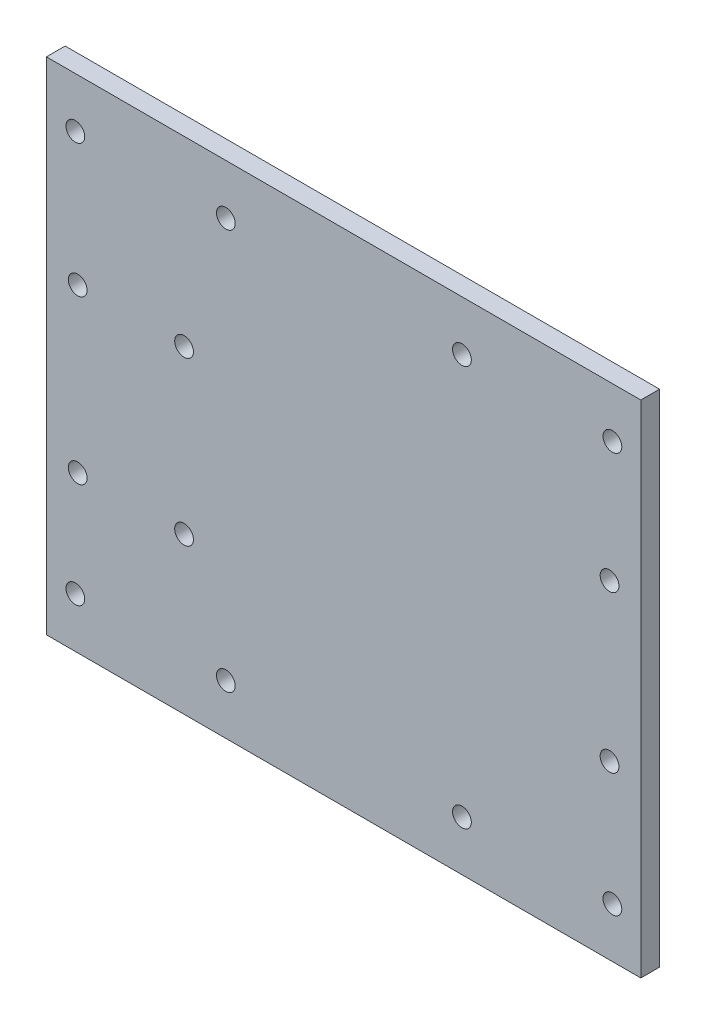
from build123d import *

# Parameters (mm, degrees)
SKETCH1_W           = 95
SKETCH1_H           = 80
BOSS_EXTRUDE1_DEPTH = 3
SKETCH2_R           = 1.5
CUT_EXTRUDE1_DEPTH  = 3


with BuildPart() as part:
    # Sketch1 → Boss-Extrude1 (new body)
    with BuildSketch(Plane.XY):
        Rectangle(SKETCH1_W, SKETCH1_H)
    extrude(amount=BOSS_EXTRUDE1_DEPTH)

    # Sketch2 → Cut-Extrude1 (cut)
    with BuildSketch(Plane.XY.offset(3)):
        with Locations((-42.875692348, -32)):
            Circle(SKETCH2_R)
        with Locations((-18.825692348, -32)):
            Circle(SKETCH2_R)
        with Locations((-42.875692348, 32)):
            Circle(SKETCH2_R)
        with Locations((-18.825692348, 32)):
            Circle(SKETCH2_R)
        with Locations((-42.5, 10.92769595)):
            Circle(SKETCH2_R)
        with Locations((-25.5, 10.92769595)):
            Circle(SKETCH2_R)
        with Locations((-42.5, -15.07230405)):
            Circle(SKETCH2_R)
        with Locations((-25.5, -15.07230405)):
            Circle(SKETCH2_R)
        with Locations((42.5, -12.5)):
            Circle(SKETCH2_R)
        with Locations((42.5, 12.5)):
            Circle(SKETCH2_R)
        with Locations((18.909687324, 32)):
            Circle(SKETCH2_R)
        with Locations((42.959687324, 32)):
            Circle(SKETCH2_R)
        with Locations((18.909687324, -32)):
            Circle(SKETCH2_R)
        with Locations((42.959687324, -32)):
            Circle(SKETCH2_R)
    extrude(amount=-CUT_EXTRUDE1_DEPTH, mode=Mode.SUBTRACT)


solid = part.part
